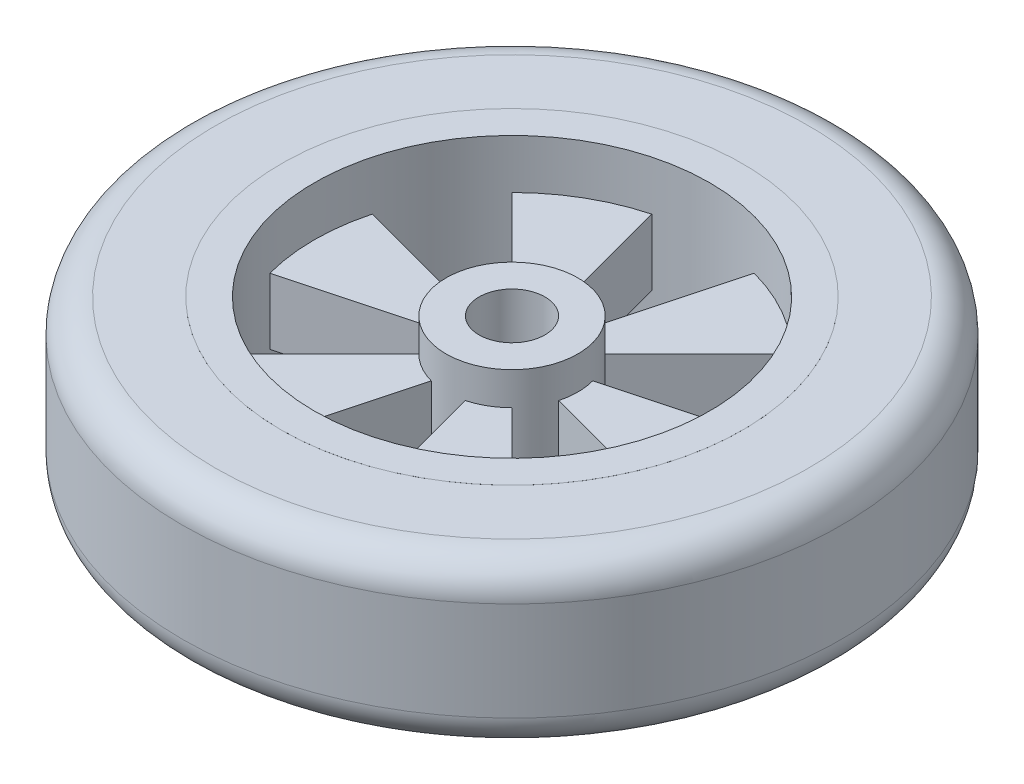
from build123d import *

# Parameters (mm, degrees)
EXTRUDE_1_DEPTH          = 10
EXTRUDE_1_DEPTH_BACK     = 10
SKETCH_1_R               = 70
EXTRUDE_2_DEPTH          = 20
EXTRUDE_2_DEPTH_BACK     = 20
SKETCH_2_R               = 20
EXTRUDE_3_DEPTH          = 25
EXTRUDE_3_DEPTH_BACK     = 25
SKETCH_3_R               = 70
SKETCH_3_R_2             = 60
CUT_EXTRUDE_1_DEPTH      = 25
CUT_EXTRUDE_1_DEPTH_BACK = 25
SKETCH_4_R               = 10
CUT_EXTRUDE_2_DEPTH      = 25
PATTERN_CIRCULAR_1_COUNT = 6
EXTRUDE_4_DEPTH          = 24.99
EXTRUDE_4_DEPTH_BACK     = 24.99
SKETCH_6_R               = 100
SKETCH_6_R_2             = 70
FILLET_1_R               = 10


with BuildPart() as part:
    # 草图1 → 凸台-拉伸1 (new, two sides: drawn at the far end of the back side and taken through both)
    with BuildSketch(Plane(origin=(0, 0, 0), x_dir=(1, 0, 0), z_dir=(0, 1, 0)).offset(-EXTRUDE_1_DEPTH_BACK)):
        Circle(SKETCH_1_R)
    extrude(amount=EXTRUDE_1_DEPTH + EXTRUDE_1_DEPTH_BACK)



with BuildPart() as body_2:
    # 草图2 → 凸台-拉伸2 (new, two sides: drawn at the far end of the back side and taken through both)
    with BuildSketch(Plane(origin=(0, 0, 0), x_dir=(1, 0, 0), z_dir=(0, 1, 0)).offset(-EXTRUDE_2_DEPTH_BACK)):
        Circle(SKETCH_2_R)
    extrude(amount=EXTRUDE_2_DEPTH + EXTRUDE_2_DEPTH_BACK)


with BuildPart() as part_1:
    add(part.part)

    add(body_2.part)  # 凸台-拉伸3 merges body 2
    # 草图3 → 凸台-拉伸3 (add, two sides: drawn at the far end of the back side and taken through both)
    with BuildSketch(Plane(origin=(0, 0, 0), x_dir=(1, 0, 0), z_dir=(0, 1, 0)).offset(-EXTRUDE_3_DEPTH_BACK)):
        Circle(SKETCH_3_R)
        Circle(SKETCH_3_R_2, mode=Mode.SUBTRACT)
    extrude(amount=EXTRUDE_3_DEPTH + EXTRUDE_3_DEPTH_BACK)

    # 草图4 → 切除-拉伸1 (cut, two sides: drawn at the far end of the back side and taken through both)
    with BuildSketch(Plane(origin=(0, 0, 0), x_dir=(1, 0, 0), z_dir=(0, 1, 0)).offset(-CUT_EXTRUDE_1_DEPTH_BACK)):
        Circle(SKETCH_4_R)
    extrude(amount=CUT_EXTRUDE_1_DEPTH + CUT_EXTRUDE_1_DEPTH_BACK, mode=Mode.SUBTRACT)

    # 草图5 → 切除-拉伸2 (cut, symmetric)
    with BuildSketch(Plane(origin=(0, 0, 0), x_dir=(1, 0, 0), z_dir=(0, 1, 0))):
        with BuildLine():
            Line((5.176381, 19.318517), (15.529143, 57.95555))
            ThreePointArc((15.529143, 57.95555), (0, 60), (-15.529143, 57.95555))
            Line((-15.529143, 57.95555), (-5.176381, 19.318517))
            ThreePointArc((-5.176381, 19.318517), (0, 20), (5.176381, 19.318517))
        make_face()
    cut_extrude_2 = extrude(amount=CUT_EXTRUDE_2_DEPTH, both=True, mode=Mode.SUBTRACT)

    # 阵列(圆周)1: 切除-拉伸2 ×6 about axis
    pattern_circular_1_axis = Axis((0, 20, 0), (0, -1, 0))
    for i in range(1, PATTERN_CIRCULAR_1_COUNT):
        add(cut_extrude_2.rotate(pattern_circular_1_axis, i * 360 / PATTERN_CIRCULAR_1_COUNT), mode=Mode.SUBTRACT)

    # 草图6 → 凸台-拉伸4 (add, two sides: drawn at the far end of the back side and taken through both)
    with BuildSketch(Plane(origin=(0, 0, 0), x_dir=(1, 0, 0), z_dir=(0, 1, 0)).offset(-EXTRUDE_4_DEPTH_BACK)):
        Circle(SKETCH_6_R)
        Circle(SKETCH_6_R_2, mode=Mode.SUBTRACT)
    extrude(amount=EXTRUDE_4_DEPTH + EXTRUDE_4_DEPTH_BACK)

    # 圆角1
    fillet_1_edges = [part_1.edges().sort_by_distance(p)[0] for p in [
        (-100, -24.99, 0),
        (-100, 24.99, 0),
    ]]
    fillet(fillet_1_edges, radius=FILLET_1_R)


solid = part_1.part
